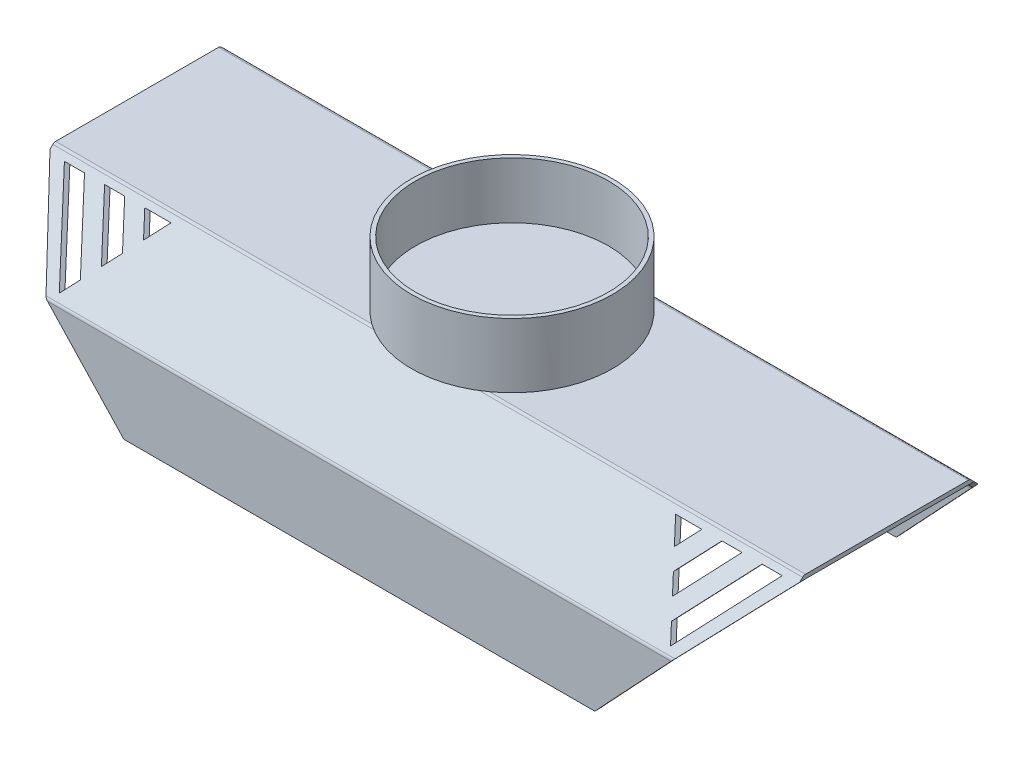
from build123d import *

# Parameters (mm, degrees)
BOSS_EXTRUDE1_DEPTH = 592.455
CUT_EXTRUDE1_DEPTH  = 482.6
BOSS_EXTRUDE2_DEPTH = 6.35
BOSS_EXTRUDE3_DEPTH = 6.35
SKETCH5_R           = 158.75
BOSS_EXTRUDE4_DEPTH = 12.7
SKETCH6_R           = 158.75
SKETCH6_R_2         = 152.4
BOSS_EXTRUDE5_DEPTH = 88.9


with BuildPart() as part:
    # Sketch1 → Boss-Extrude1 (new body, symmetric)
    with BuildSketch(Plane(origin=(0, 0, 0), x_dir=(0, 0, -1), z_dir=(1, 0, 0))):
        with BuildLine():
            Line((128.652963539, -19.049996224), (-128.652963539, -19.049996224))
            ThreePointArc((-128.652963539, -19.049996224), (-131.083003335, -19.533361193), (-133.1430916, -20.909868164))
            Line((-133.1430916, -20.909868164), (-239.440128061, -127.206904624))
            ThreePointArc((-239.440128061, -127.206904624), (-240.816635031, -129.266992889), (-241.3, -131.697032685))
            Line((-241.3, -131.697032685), (-241.3, -253.999996224))
            Line((-241.3, -253.999996224), (-234.95, -253.999996224))
            Line((-234.95, -253.999996224), (-234.95, -134.327288806))
            ThreePointArc((-234.95, -134.327288806), (-234.466635031, -131.89724901), (-233.090128061, -129.837160745))
            Line((-233.090128061, -129.837160745), (-130.512835479, -27.259868164))
            ThreePointArc((-130.512835479, -27.259868164), (-128.452747214, -25.883361193), (-126.022707418, -25.399996224))
            Line((-126.022707418, -25.399996224), (126.022707418, -25.399996224))
            ThreePointArc((126.022707418, -25.399996224), (128.452747214, -25.883361193), (130.512835479, -27.259868164))
            Line((130.512835479, -27.259868164), (233.090128061, -129.837160745))
            ThreePointArc((233.090128061, -129.837160745), (234.466635031, -131.89724901), (234.95, -134.327288806))
            Line((234.95, -134.327288806), (234.95, -253.999996224))
            Line((234.95, -253.999996224), (241.3, -253.999996224))
            Line((241.3, -253.999996224), (241.3, -131.697032685))
            ThreePointArc((241.3, -131.697032685), (240.816635031, -129.266992889), (239.440128061, -127.206904624))
            Line((239.440128061, -127.206904624), (133.1430916, -20.909868164))
            ThreePointArc((133.1430916, -20.909868164), (131.083003335, -19.533361193), (128.652963539, -19.049996224))
        make_face()
    extrude(amount=BOSS_EXTRUDE1_DEPTH, both=True)

    # Sketch2 → Cut-Extrude1 (cut)
    with BuildSketch(Plane(origin=(0, 0, -241.3), x_dir=(-1, 0, 0), z_dir=(0, 0, -1))):
        Polygon((-592.455, -253.999996224), (-378.079, -253.999996224), (-592.455, -25.399996224), align=None)
        Polygon((-535.401348451, -27.939996224), (-467.080186427, -102.818047021), (-482.955186427, -120.216595599), (-567.151348451, -27.939996224), align=None)
        Polygon((-398.759024402, -27.939996224), (-419.455186427, -50.622401287), (-440.151348451, -27.939996224), align=None)
        Polygon((-503.651348451, -27.939996224), (-451.205186427, -85.419498443), (-435.330186427, -68.020949865), (-471.901348451, -27.939996224), align=None)
        Polygon((398.759024402, -27.939996224), (440.151348451, -27.939996224), (419.455186427, -50.622401287), align=None)
        Polygon((471.901348451, -27.939996224), (503.651348451, -27.939996224), (451.205186427, -85.419498443), (435.330186427, -68.020949865), align=None)
        Polygon((535.401348451, -27.939996224), (567.151348451, -27.939996224), (482.955186427, -120.216595599), (467.080186427, -102.818047021), align=None)
        Polygon((592.455, -25.399996224), (592.455, -253.999996224), (378.079, -253.999996224), align=None)
    extrude(amount=-CUT_EXTRUDE1_DEPTH, mode=Mode.SUBTRACT)

    # Sketch3 → Boss-Extrude2 (add)
    with BuildSketch(Plane(origin=(0, 0, -241.3), x_dir=(-1, 0, 0), z_dir=(0, 0, -1))):
        Polygon((-372.124111111, -260.349996224), (372.124111111, -260.349996224), (378.079, -253.999996224), (-378.079, -253.999996224), align=None)
    extrude(amount=-BOSS_EXTRUDE2_DEPTH)

    # Sketch4 → Boss-Extrude3 (add)
    with BuildSketch(Plane.XY.offset(241.3)):
        Polygon((-372.124111111, -260.349996224), (372.124111111, -260.349996224), (378.079, -253.999996224), (-378.079, -253.999996224), align=None)
    extrude(amount=-BOSS_EXTRUDE3_DEPTH)

    # Sketch5 → Boss-Extrude4 (add)
    with BuildSketch(Plane(origin=(0, -19.049996224, 0), x_dir=(1, 0, 0), z_dir=(0, 1, 0))):
        Circle(SKETCH5_R)
    extrude(amount=BOSS_EXTRUDE4_DEPTH)

    # Sketch6 → Boss-Extrude5 (add)
    with BuildSketch(Plane(origin=(0, -6.349996224, 0), x_dir=(1, 0, 0), z_dir=(0, 1, 0))):
        Circle(SKETCH6_R)
        Circle(SKETCH6_R_2, mode=Mode.SUBTRACT)
    extrude(amount=BOSS_EXTRUDE5_DEPTH)


solid = part.part
